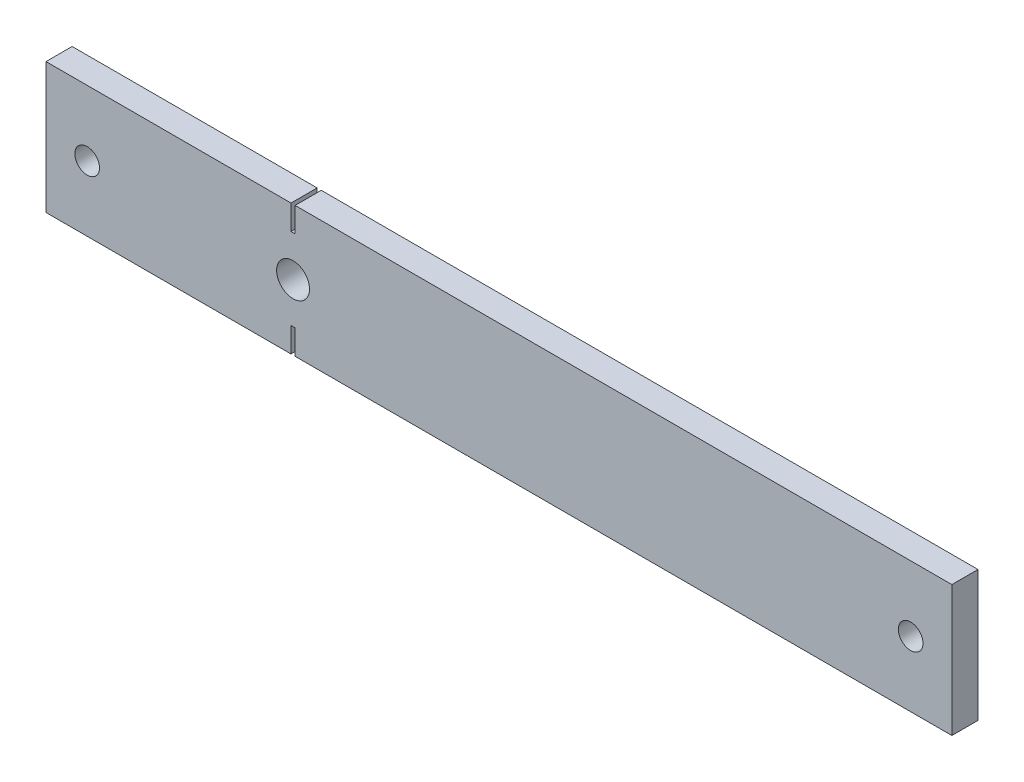
from build123d import *

# Parameters (mm, degrees)
SKETCH1_R           = 3
SKETCH1_R_2         = 4
BOSS_EXTRUDE1_DEPTH = 6.35


with BuildPart() as part:
    # Sketch1 → Boss-Extrude1 (new body)
    with BuildSketch(Plane.XY):
        Polygon((60.5, 31.75), (220, 31.75), (220, 0), (60.5, 0), (60.5, 6), (59.5, 6), (59.5, 0), (0, 0), (0, 31.75), (59.5, 31.75), (59.5, 25.75), (60.5, 25.75), align=None)
        with Locations((10, 15.875)):
            Circle(SKETCH1_R, mode=Mode.SUBTRACT)
        with Locations((60, 15.875)):
            Circle(SKETCH1_R_2, mode=Mode.SUBTRACT)
        with Locations((210, 15.875)):
            Circle(SKETCH1_R, mode=Mode.SUBTRACT)
    extrude(amount=BOSS_EXTRUDE1_DEPTH)


solid = part.part
